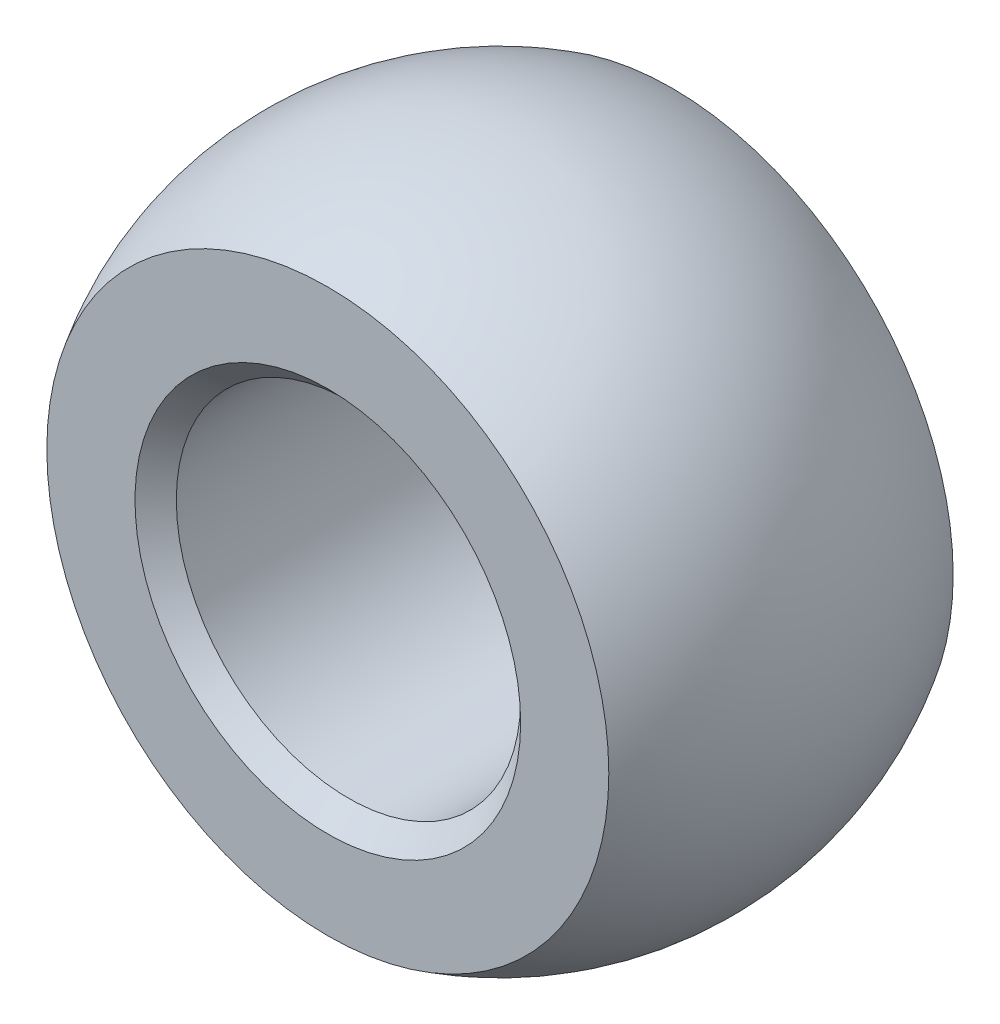
from build123d import *

# Parameters (mm, degrees)
CUT_EXTRUDE3_DEPTH      = 22.05117231
CUT_EXTRUDE3_DEPTH_BACK = 22.05117231
SKETCH8_W               = 15.875
SKETCH8_H               = 101.6
CUT_EXTRUDE4_DEPTH      = 22.05117231
CUT_EXTRUDE4_DEPTH_BACK = 22.05117231
SKETCH10_R              = 6.35
CHAMFER1_SIZE           = 0.762
SCALE1_SCALE            = 0.75
SCALE2_SCALE            = 0.666666667


with BuildPart() as part:
    # Sketch7 → Revolve1 (revolve)
    with BuildSketch(Plane.XY):
        with BuildLine():
            Line((0, 12.1539), (0, -12.1539))
            ThreePointArc((0, -12.1539), (12.1539, 0), (0, 12.1539))
        make_face()
    revolve(axis=Axis((0, 22.114519505, 0), (0, -1, 0)))

    # Sketch8 → Cut-Extrude3 (cut, two sides: drawn at the far end of the back side and taken through both)
    with BuildSketch(Plane(origin=(0, 0, 0), x_dir=(0, 0, -1), z_dir=(1, 0, 0)).offset(-CUT_EXTRUDE3_DEPTH_BACK)):
        with Locations((-14.2875, 0)):
            Rectangle(SKETCH8_W, SKETCH8_H)
        with Locations((14.2875, 0)):
            Rectangle(SKETCH8_W, SKETCH8_H)
    extrude(amount=CUT_EXTRUDE3_DEPTH + CUT_EXTRUDE3_DEPTH_BACK, mode=Mode.SUBTRACT)

    # Sketch10 → Cut-Extrude4 (cut, two sides: drawn at the far end of the back side and taken through both)
    with BuildSketch(Plane.XY.offset(-CUT_EXTRUDE4_DEPTH_BACK)):
        Circle(SKETCH10_R)
    extrude(amount=CUT_EXTRUDE4_DEPTH + CUT_EXTRUDE4_DEPTH_BACK, mode=Mode.SUBTRACT)

    # Chamfer1
    chamfer1_edges = [part.edges().sort_by_distance(p)[0] for p in [
        (-6.35, 0, -6.35),
        (-6.35, 0, 6.35),
    ]]
    chamfer(chamfer1_edges, length=CHAMFER1_SIZE)


with BuildPart() as part_1:
    # Scale1: scaled about (1.5e-08, 9.4e-08, 0)
    add(part.part.scale(SCALE1_SCALE).moved(Location((4e-09, 2.3e-08, 0))))


with BuildPart() as part_2:
    # Scale2: scaled about (1.5e-08, 9.4e-08, 0)
    add(part_1.part.scale(SCALE2_SCALE).moved(Location((5e-09, 3.1e-08, 0))))


solid = part_2.part
